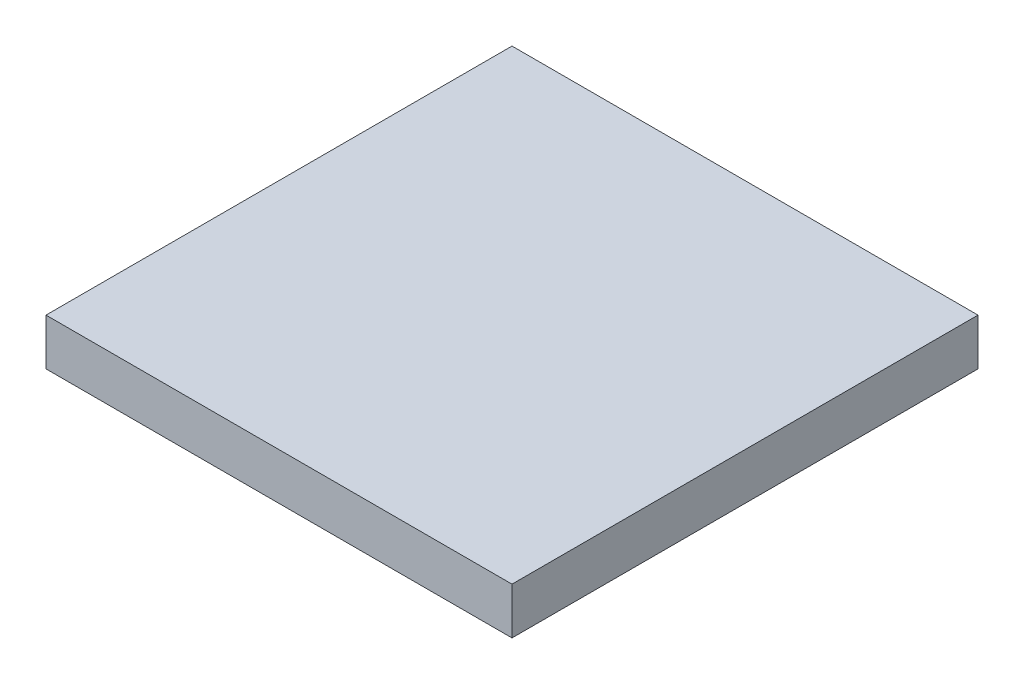
from build123d import *

# Parameters (mm, degrees)
SKETCH1_R              = 2.035533906
SKETCH1_R_2            = 1.5
BOSS_EXTRUDE1_DEPTH    = 1
SKETCH1_W              = 20
SKETCH1_H              = 20
SKETCH1_W_2            = 18
SKETCH1_H_2            = 18
BOSS_EXTRUDE1_2_DEPTH  = 1
BOSS_EXTRUDE1_3_DEPTH  = 1
BOSS_EXTRUDE1_4_DEPTH  = 1
BOSS_EXTRUDE1_5_DEPTH  = 1
BOSS_EXTRUDE1_6_DEPTH  = 1
BOSS_EXTRUDE1_7_DEPTH  = 1
BOSS_EXTRUDE1_8_DEPTH  = 1
BOSS_EXTRUDE1_9_DEPTH  = 1
BOSS_EXTRUDE1_10_DEPTH = 1
SKETCH1_3_W            = 20
SKETCH1_3_H            = 20
BOSS_EXTRUDE2_DEPTH    = 1


with BuildPart() as part:
    # Sketch1 → Boss-Extrude1 (new body)
    with BuildSketch(Plane(origin=(0, 0, 0), x_dir=(1, 0, 0), z_dir=(0, 1, 0))):
        with Locations((5, 15)):
            Circle(SKETCH1_R)
        with Locations((5, 15)):
            Circle(SKETCH1_R_2, mode=Mode.SUBTRACT)
    extrude(amount=-BOSS_EXTRUDE1_DEPTH)



with BuildPart() as body_2:
    # Sketch1 → Boss-Extrude1 2 (new body)
    with BuildSketch(Plane(origin=(0, 0, 0), x_dir=(1, 0, 0), z_dir=(0, 1, 0))):
        with Locations((10, 10)):
            Rectangle(SKETCH1_W, SKETCH1_H)
        with Locations((10, 10)):
            Rectangle(SKETCH1_W_2, SKETCH1_H_2, mode=Mode.SUBTRACT)
    extrude(amount=-BOSS_EXTRUDE1_2_DEPTH)


with BuildPart() as body_3:
    # Sketch1 → Boss-Extrude1 3 (new body)
    with BuildSketch(Plane(origin=(0, 0, 0), x_dir=(1, 0, 0), z_dir=(0, 1, 0))):
        with Locations((5, 10)):
            Circle(SKETCH1_R)
        with Locations((5, 10)):
            Circle(SKETCH1_R_2, mode=Mode.SUBTRACT)
    extrude(amount=-BOSS_EXTRUDE1_3_DEPTH)


with BuildPart() as body_4:
    # Sketch1 → Boss-Extrude1 4 (new body)
    with BuildSketch(Plane(origin=(0, 0, 0), x_dir=(1, 0, 0), z_dir=(0, 1, 0))):
        with Locations((10, 15)):
            Circle(SKETCH1_R)
        with Locations((10, 15)):
            Circle(SKETCH1_R_2, mode=Mode.SUBTRACT)
    extrude(amount=-BOSS_EXTRUDE1_4_DEPTH)


with BuildPart() as body_5:
    # Sketch1 → Boss-Extrude1 5 (new body)
    with BuildSketch(Plane(origin=(0, 0, 0), x_dir=(1, 0, 0), z_dir=(0, 1, 0))):
        with Locations((5, 5)):
            Circle(SKETCH1_R)
        with Locations((5, 5)):
            Circle(SKETCH1_R_2, mode=Mode.SUBTRACT)
    extrude(amount=-BOSS_EXTRUDE1_5_DEPTH)


with BuildPart() as body_6:
    # Sketch1 → Boss-Extrude1 6 (new body)
    with BuildSketch(Plane(origin=(0, 0, 0), x_dir=(1, 0, 0), z_dir=(0, 1, 0))):
        with Locations((10, 10)):
            Circle(SKETCH1_R)
        with Locations((10, 10)):
            Circle(SKETCH1_R_2, mode=Mode.SUBTRACT)
    extrude(amount=-BOSS_EXTRUDE1_6_DEPTH)


with BuildPart() as body_7:
    # Sketch1 → Boss-Extrude1 7 (new body)
    with BuildSketch(Plane(origin=(0, 0, 0), x_dir=(1, 0, 0), z_dir=(0, 1, 0))):
        with Locations((15, 15)):
            Circle(SKETCH1_R)
        with Locations((15, 15)):
            Circle(SKETCH1_R_2, mode=Mode.SUBTRACT)
    extrude(amount=-BOSS_EXTRUDE1_7_DEPTH)


with BuildPart() as body_8:
    # Sketch1 → Boss-Extrude1 8 (new body)
    with BuildSketch(Plane(origin=(0, 0, 0), x_dir=(1, 0, 0), z_dir=(0, 1, 0))):
        with Locations((10, 5)):
            Circle(SKETCH1_R)
        with Locations((10, 5)):
            Circle(SKETCH1_R_2, mode=Mode.SUBTRACT)
    extrude(amount=-BOSS_EXTRUDE1_8_DEPTH)


with BuildPart() as body_9:
    # Sketch1 → Boss-Extrude1 9 (new body)
    with BuildSketch(Plane(origin=(0, 0, 0), x_dir=(1, 0, 0), z_dir=(0, 1, 0))):
        with Locations((15, 10)):
            Circle(SKETCH1_R)
        with Locations((15, 10)):
            Circle(SKETCH1_R_2, mode=Mode.SUBTRACT)
    extrude(amount=-BOSS_EXTRUDE1_9_DEPTH)


with BuildPart() as body_10:
    # Sketch1 → Boss-Extrude1 10 (new body)
    with BuildSketch(Plane(origin=(0, 0, 0), x_dir=(1, 0, 0), z_dir=(0, 1, 0))):
        with Locations((15, 5)):
            Circle(SKETCH1_R)
        with Locations((15, 5)):
            Circle(SKETCH1_R_2, mode=Mode.SUBTRACT)
    extrude(amount=-BOSS_EXTRUDE1_10_DEPTH)


with BuildPart() as part_1:
    add(part.part)

    add(body_2.part)  # Boss-Extrude2 merges body 2

    add(body_3.part)  # Boss-Extrude2 merges body 3

    add(body_4.part)  # Boss-Extrude2 merges body 4

    add(body_5.part)  # Boss-Extrude2 merges body 5

    add(body_6.part)  # Boss-Extrude2 merges body 6

    add(body_7.part)  # Boss-Extrude2 merges body 7

    add(body_8.part)  # Boss-Extrude2 merges body 8

    add(body_9.part)  # Boss-Extrude2 merges body 9

    add(body_10.part)  # Boss-Extrude2 merges body 10
    # Sketch1_3 → Boss-Extrude2 (add)
    with BuildSketch(Plane(origin=(0, 0, 0), x_dir=(1, 0, 0), z_dir=(0, 1, 0))):
        with Locations((10, 10)):
            Rectangle(SKETCH1_3_W, SKETCH1_3_H)
    extrude(amount=BOSS_EXTRUDE2_DEPTH)


solid = part_1.part
